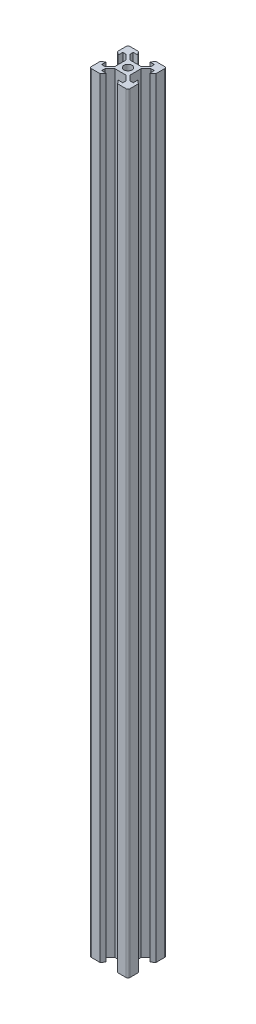
from build123d import *

# Parameters (mm, degrees)
SKETCH1_R           = 2.1
BOSS_EXTRUDE1_DEPTH = 400


with BuildPart() as part:
    # Sketch1 → Boss-Extrude1 (new body)
    with BuildSketch(Plane(origin=(0, 0, 0), x_dir=(1, 0, 0), z_dir=(0, 1, 0))):
        with BuildLine():
            Line((-5.5, 8.2), (-3.125, 8.2))
            Line((-3.125, 8.2), (-4.58, 10))
            Line((-4.58, 10), (-9, 10))
            ThreePointArc((-9, 10), (-9.707106781, 9.707106781), (-10, 9))
            Line((-10, 9), (-10, 4.58))
            Line((-10, 4.58), (-8.2, 3.125))
            Line((-8.2, 3.125), (-8.2, 5.5))
            Line((-8.2, 5.5), (-6.56, 5.5))
            Line((-6.56, 5.5), (-3.9, 2.84))
            Line((-3.9, 2.84), (-3.9, -2.84))
            Line((-3.9, -2.84), (-6.56, -5.5))
            Line((-6.56, -5.5), (-8.2, -5.5))
            Line((-8.2, -5.5), (-8.2, -3.125))
            Line((-8.2, -3.125), (-10, -4.58))
            Line((-10, -4.58), (-10, -9))
            ThreePointArc((-10, -9), (-9.707106781, -9.707106781), (-9, -10))
            Line((-9, -10), (-4.58, -10))
            Line((-4.58, -10), (-3.125, -8.2))
            Line((-3.125, -8.2), (-5.5, -8.2))
            Line((-5.5, -8.2), (-5.5, -6.56))
            Line((-5.5, -6.56), (-2.84, -3.9))
            Line((-2.84, -3.9), (2.84, -3.9))
            Line((2.84, -3.9), (5.5, -6.56))
            Line((5.5, -6.56), (5.5, -8.2))
            Line((5.5, -8.2), (3.125, -8.2))
            Line((3.125, -8.2), (4.58, -10))
            Line((4.58, -10), (9, -10))
            ThreePointArc((9, -10), (9.707106781, -9.707106781), (10, -9))
            Line((10, -9), (10, -4.58))
            Line((10, -4.58), (8.2, -3.125))
            Line((8.2, -3.125), (8.2, -5.5))
            Line((8.2, -5.5), (6.56, -5.5))
            Line((6.56, -5.5), (3.9, -2.84))
            Line((3.9, -2.84), (3.9, 2.84))
            Line((3.9, 2.84), (6.56, 5.5))
            Line((6.56, 5.5), (8.2, 5.5))
            Line((8.2, 5.5), (8.2, 3.125))
            Line((8.2, 3.125), (10, 4.58))
            Line((10, 4.58), (10, 9))
            ThreePointArc((10, 9), (9.707106781, 9.707106781), (9, 10))
            Line((9, 10), (4.58, 10))
            Line((4.58, 10), (3.125, 8.2))
            Line((3.125, 8.2), (5.5, 8.2))
            Line((5.5, 8.2), (5.5, 6.56))
            Line((5.5, 6.56), (2.84, 3.9))
            Line((2.84, 3.9), (-2.84, 3.9))
            Line((-2.84, 3.9), (-5.5, 6.56))
            Line((-5.5, 6.56), (-5.5, 8.2))
        make_face()
        Circle(SKETCH1_R, mode=Mode.SUBTRACT)
    extrude(amount=BOSS_EXTRUDE1_DEPTH)


solid = part.part
